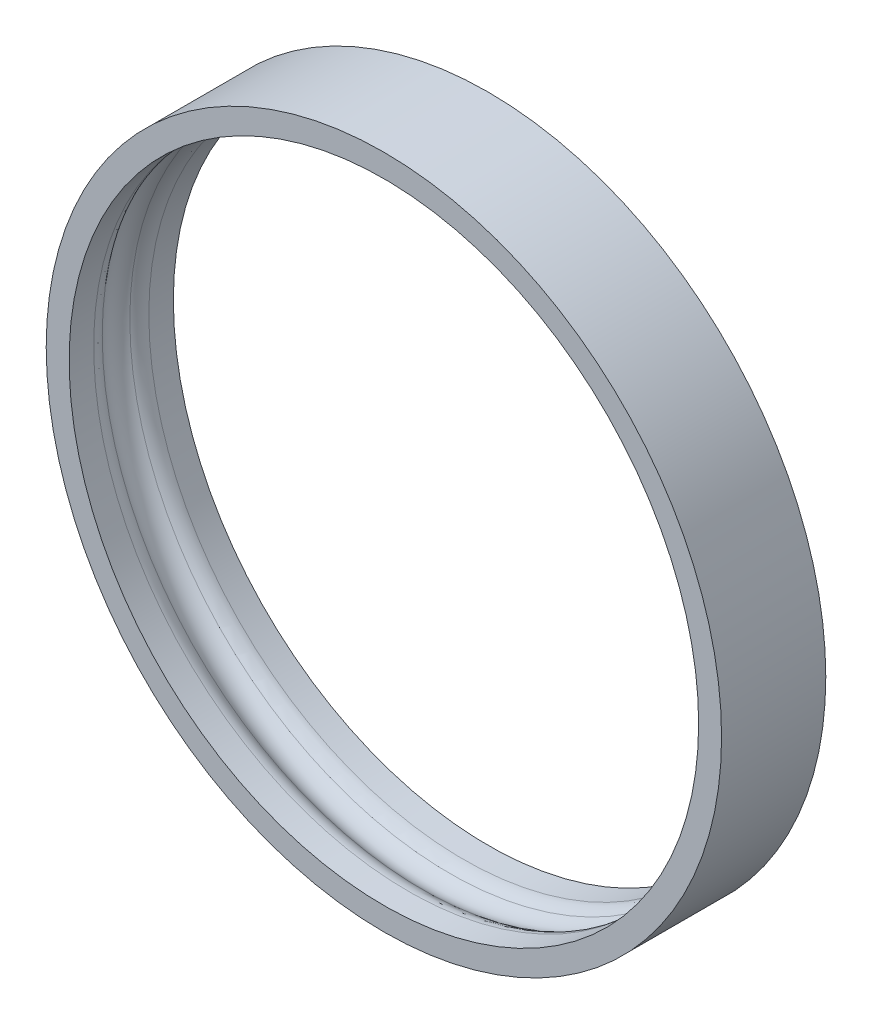
from build123d import *

# Parameters (mm, degrees)
SKETCH_1_R      = 16.2
SKETCH_1_R_2    = 15.1
EXTRUDE_1_DEPTH = 2.5
SKETCH_3_R      = 1
FILLET_1_R      = 1


with BuildPart() as part:
    # 草图1 → 凸台-拉伸1 (new body, symmetric)
    with BuildSketch(Plane.XY):
        Circle(SKETCH_1_R)
        Circle(SKETCH_1_R_2, mode=Mode.SUBTRACT)
    extrude(amount=EXTRUDE_1_DEPTH, both=True)

    # 草图3 → 切除-旋转1 (revolve, cut)
    with BuildSketch(Plane(origin=(0, 0, 0), x_dir=(1, 0, 0), z_dir=(0, 1, 0))):
        with Locations((-14.6, 0)):
            Circle(SKETCH_3_R)
    revolve(axis=Axis((0, 0, 2.5), (0, 0, -1)), mode=Mode.SUBTRACT)

    # 圆角1
    fillet_1_edges = [part.edges().sort_by_distance(p)[0] for p in [
        (0, 15.1, 0.866025404),
        (0, -15.1, -0.866025404),
    ]]
    fillet(fillet_1_edges, radius=FILLET_1_R)


solid = part.part
